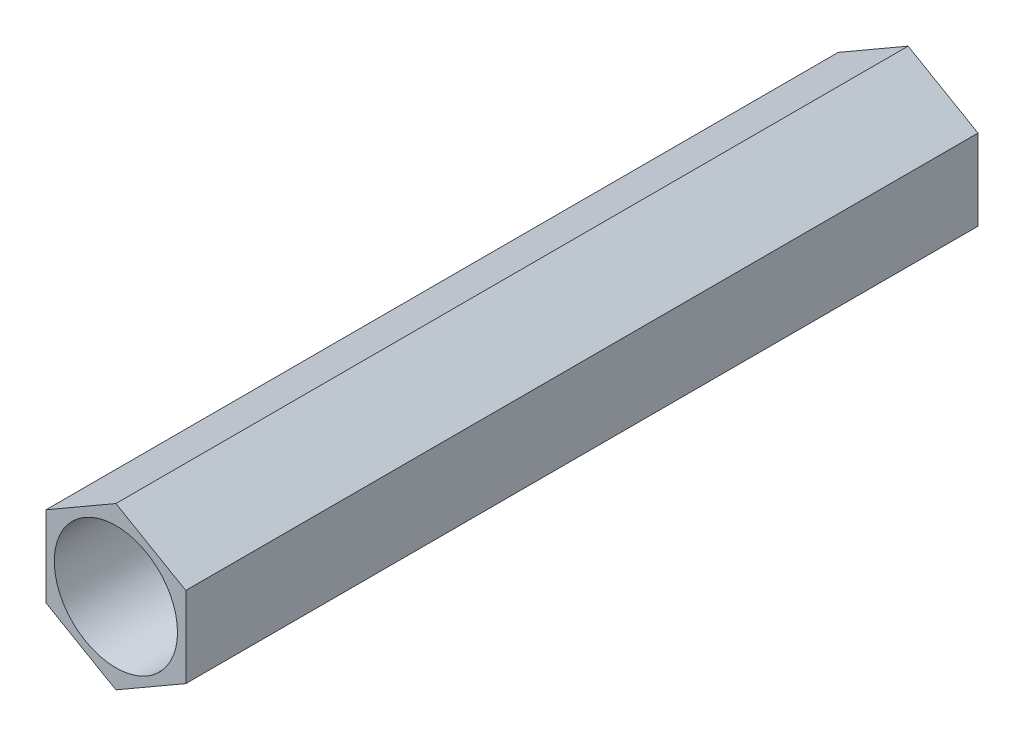
from build123d import *

# Parameters (mm, degrees)
SKETCH1_R      = 2.1
EXTRUDE1_DEPTH = 27


with BuildPart() as part:
    # Sketch1 → Extrude1 (new body)
    with BuildSketch(Plane.XY):
        Polygon((0, -2.75), (2.38156986, -1.375), (2.38156986, 1.375), (0, 2.75), (-2.38156986, 1.375), (-2.38156986, -1.375), align=None)
        Circle(SKETCH1_R, mode=Mode.SUBTRACT)
    extrude(amount=EXTRUDE1_DEPTH)


solid = part.part
